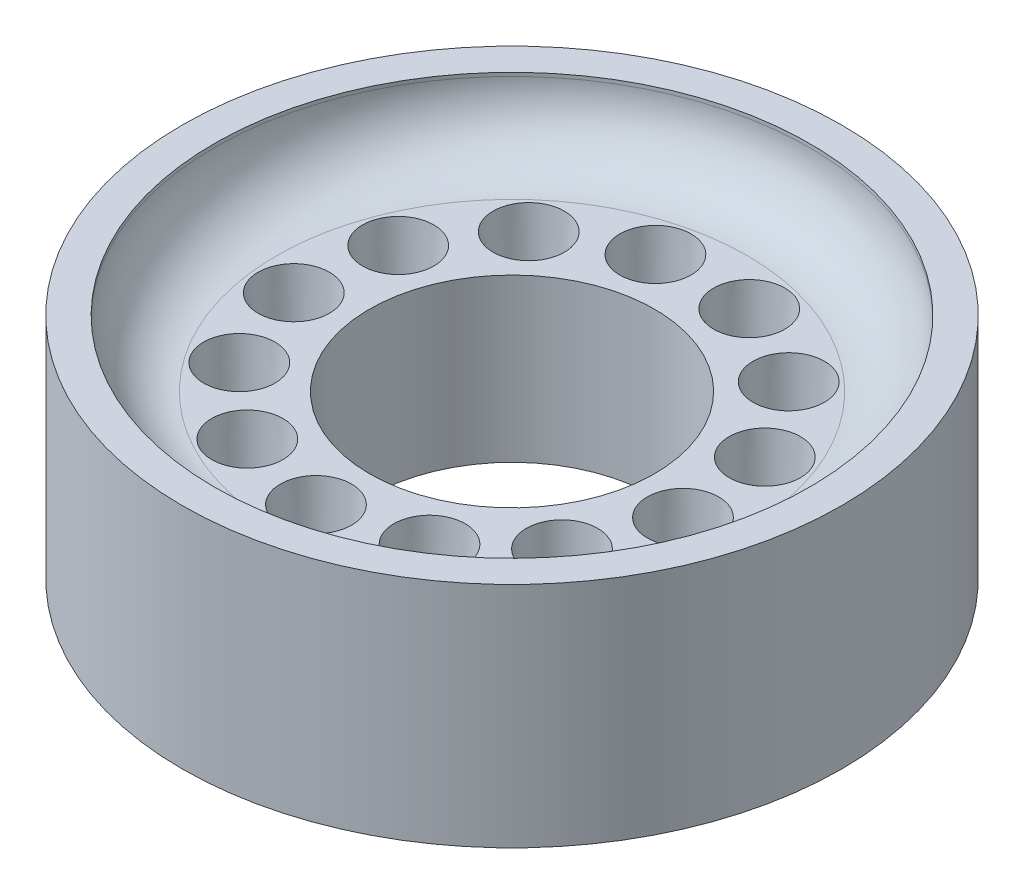
from build123d import *

# Parameters (mm, degrees)
SKETCH1_R           = 9.25
SKETCH1_R_2         = 4
BOSS_EXTRUDE1_DEPTH = 6.4
SKETCH2_R           = 8.35
CUT_EXTRUDE1_DEPTH  = 1.85
FILLET1_R           = 1.75
SKETCH3_R           = 1
CUT_EXTRUDE2_DEPTH  = 4.55
CUT_EXTRUDE2_TAPER  = 5
CIRPATTERN1_COUNT   = 13


with BuildPart() as part:
    # Sketch1 → Boss-Extrude1 (new body)
    with BuildSketch(Plane(origin=(0, 0, 0), x_dir=(1, 0, 0), z_dir=(0, 1, 0))):
        Circle(SKETCH1_R)
        Circle(SKETCH1_R_2, mode=Mode.SUBTRACT)
    extrude(amount=BOSS_EXTRUDE1_DEPTH)

    # Sketch2 → Cut-Extrude1 (cut)
    with BuildSketch(Plane(origin=(0, 6.4, 0), x_dir=(1, 0, 0), z_dir=(0, 1, 0))):
        Circle(SKETCH2_R)
    extrude(amount=-CUT_EXTRUDE1_DEPTH, mode=Mode.SUBTRACT)

    # Fillet1
    fillet1_edges = [part.edges().sort_by_distance(p)[0] for p in [
        (-8.35, 4.55, 0),
    ]]
    fillet(fillet1_edges, radius=FILLET1_R)

    # Sketch3 → Cut-Extrude2 (cut)
    with BuildSketch(Plane(origin=(0, 4.55, 0), x_dir=(1, 0, 0), z_dir=(0, 1, 0))):
        with Locations((0, -5.5)):
            Circle(SKETCH3_R)
    cut_extrude2 = extrude(amount=-CUT_EXTRUDE2_DEPTH, taper=CUT_EXTRUDE2_TAPER, mode=Mode.SUBTRACT)

    # CirPattern1: Cut-Extrude2 ×13 about axis
    cirpattern1_axis = Axis((0, 0, 0), (0, 1, 0))
    for i in range(1, CIRPATTERN1_COUNT):
        add(cut_extrude2.rotate(cirpattern1_axis, i * 360 / CIRPATTERN1_COUNT), mode=Mode.SUBTRACT)


solid = part.part
